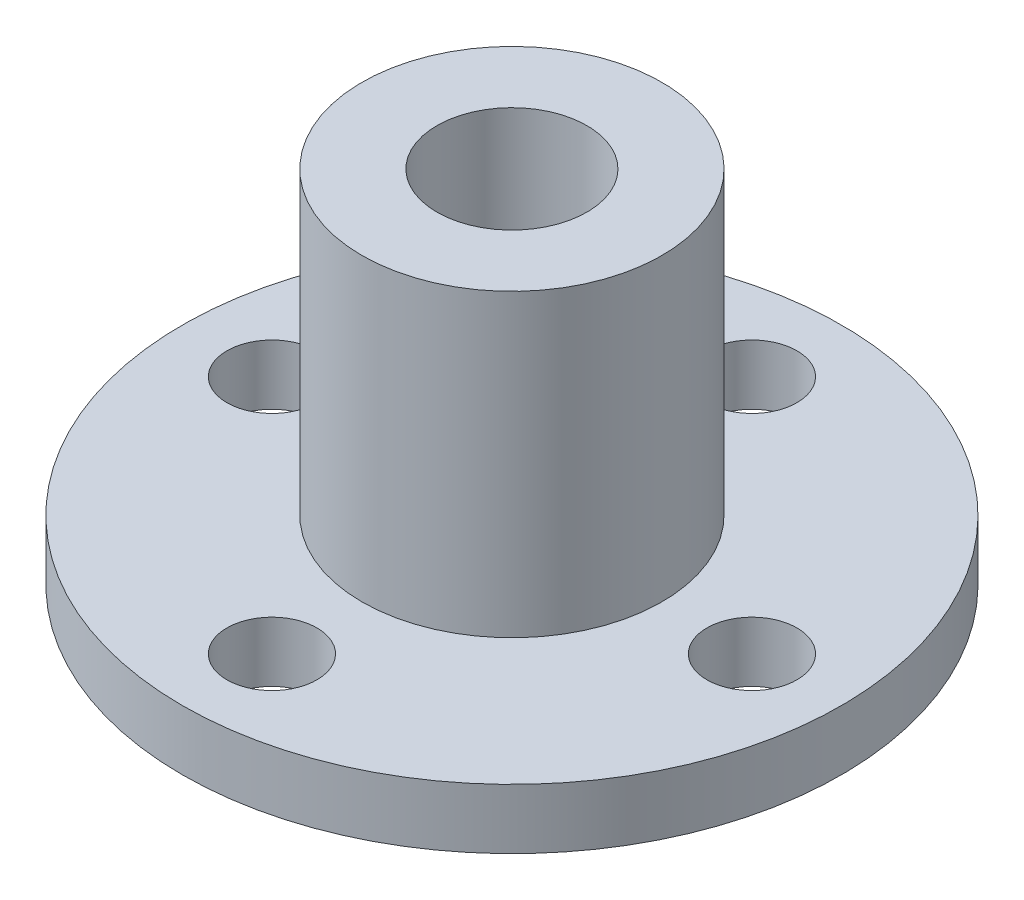
from build123d import *

# Parameters (mm, degrees)
SKETCH1_R               = 10.9855
BOSS_EXTRUDE1_DEPTH     = 2
SKETCH3_R               = 5
BOSS_EXTRUDE2_DEPTH     = 10
SKETCH2_R               = 2.5
CUT_EXTRUDE1_DEPTH      = 11
CUT_EXTRUDE1_DEPTH_BACK = 3
SKETCH4_R               = 1.5
CUT_EXTRUDE2_DEPTH      = 10


with BuildPart() as part:
    # Sketch1 → Boss-Extrude1 (new body)
    with BuildSketch(Plane(origin=(0, 0, 0), x_dir=(1, 0, 0), z_dir=(0, 1, 0))):
        Circle(SKETCH1_R)
    extrude(amount=BOSS_EXTRUDE1_DEPTH)

    # Sketch3 → Boss-Extrude2 (add)
    with BuildSketch(Plane(origin=(0, 2, 0), x_dir=(1, 0, 0), z_dir=(0, 1, 0))):
        Circle(SKETCH3_R)
    extrude(amount=BOSS_EXTRUDE2_DEPTH)

    # Sketch2 → Cut-Extrude1 (cut, two sides)
    with BuildSketch(Plane(origin=(0, 2, 0), x_dir=(1, 0, 0), z_dir=(0, 1, 0))) as cut_extrude1_sk:
        Circle(SKETCH2_R)
    extrude(amount=CUT_EXTRUDE1_DEPTH, mode=Mode.SUBTRACT)
    extrude(cut_extrude1_sk.sketch, amount=-CUT_EXTRUDE1_DEPTH_BACK, mode=Mode.SUBTRACT)

    # Sketch4 → Cut-Extrude2 (cut)
    with BuildSketch(Plane(origin=(0, 2, 0), x_dir=(1, 0, 0), z_dir=(0, 1, 0))):
        with Locations((8, 0)):
            Circle(SKETCH4_R)
        with Locations((0, -8)):
            Circle(SKETCH4_R)
        with Locations((-8, 0)):
            Circle(SKETCH4_R)
        with Locations((0, 8)):
            Circle(SKETCH4_R)
    extrude(amount=-CUT_EXTRUDE2_DEPTH, mode=Mode.SUBTRACT)


solid = part.part
